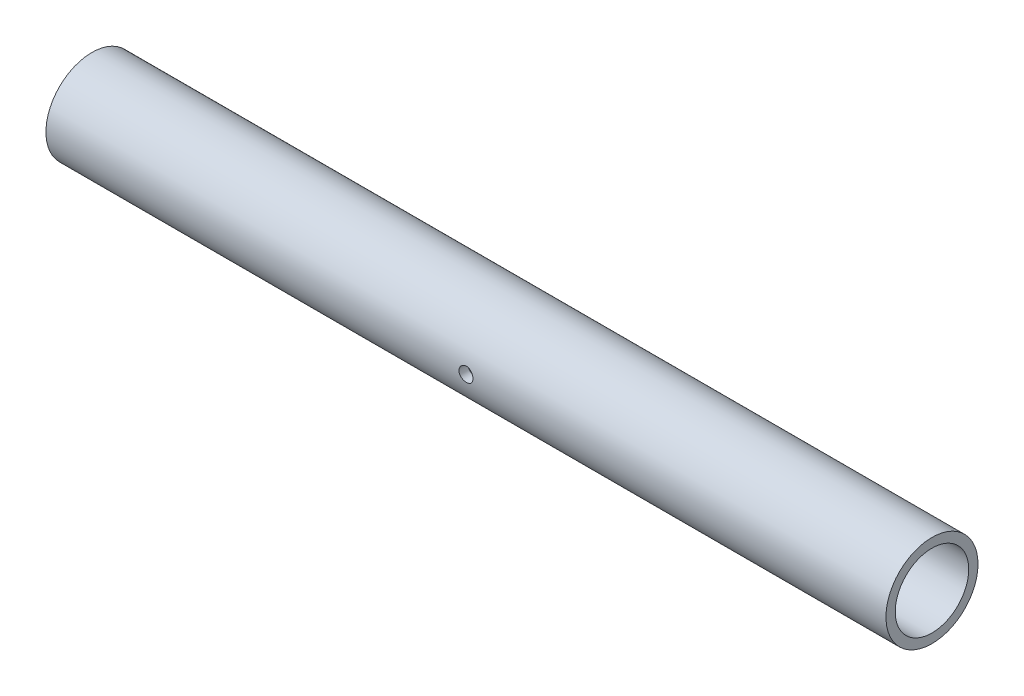
from build123d import *

# Parameters (mm, degrees)
SKETCH1_R                    = 16.7005
SKETCH1_R_2                  = 13.335
BOSS_EXTRUDE1_DEPTH          = 304.8
F_1_4_20_TAPPED_HOLE1_REACH  = 158.909
F_1_4_20_TAPPED_HOLE1_BORE_R = 2.5527


with BuildPart() as part:
    # Sketch1 → Boss-Extrude1 (new body)
    with BuildSketch(Plane(origin=(0, 0, 0), x_dir=(0, 0, -1), z_dir=(1, 0, 0))):
        with Locations(Location((0, 0, 0), (0, 0, 180))):
            Circle(SKETCH1_R)
        with Locations(Location((0, 0, 0), (0, 0, 180))):
            Circle(SKETCH1_R_2, mode=Mode.SUBTRACT)
    extrude(amount=BOSS_EXTRUDE1_DEPTH)

    # 1/4-20 Tapped Hole1 bore (on position points) → 1/4-20 Tapped Hole1 (cut, up to next)
    with BuildSketch(Plane(origin=(152.4, 0, 16.7005), x_dir=(1, 0, 0), z_dir=(0, 0, 1)), mode=Mode.PRIVATE) as f_1_4_20_tapped_hole1_sk1:
        Circle(F_1_4_20_TAPPED_HOLE1_BORE_R)
    f_1_4_20_tapped_hole1_tool1 = extrude(f_1_4_20_tapped_hole1_sk1.sketch, amount=-F_1_4_20_TAPPED_HOLE1_REACH, mode=Mode.PRIVATE) & part.part
    add(f_1_4_20_tapped_hole1_tool1.solids().sort_by_distance((152.4, 0, 16.7005))[0], mode=Mode.SUBTRACT)


solid = part.part
